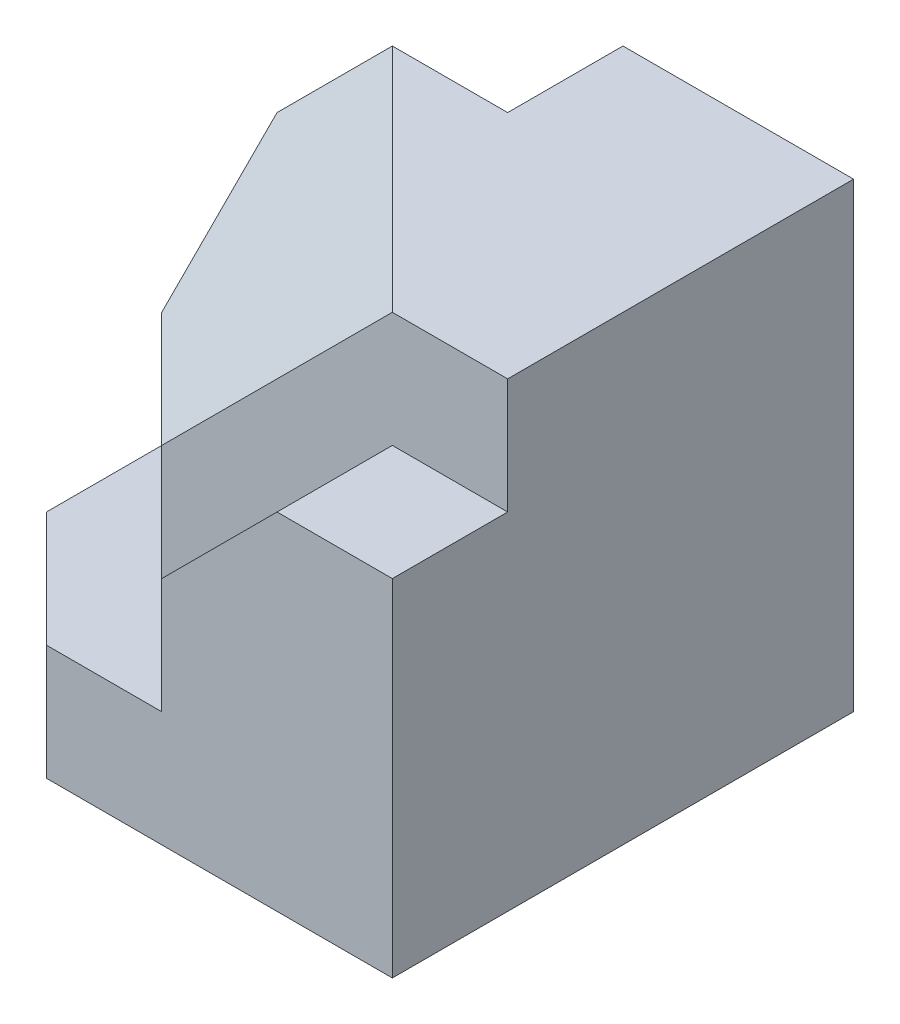
from build123d import *

# Parameters (mm, degrees)
BOSS_EXTRUDE1_DEPTH = 20
BOSS_EXTRUDE2_DEPTH = 20
CUT_EXTRUDE1_DEPTH  = 20
BOSS_EXTRUDE3_DEPTH = 5
BOSS_EXTRUDE4_DEPTH = 5
SKETCH7_W           = 5
SKETCH7_H           = 15
BOSS_EXTRUDE5_DEPTH = 10


with BuildPart() as part:
    # Sketch2 → Boss-Extrude1 (new body)
    with BuildSketch(Plane(origin=(0, 0, 0), x_dir=(1, 0, 0), z_dir=(0, 1, 0))):
        Polygon((-10, -5), (-10, 0), (0, 0), (0, -15), (-5, -15), (-15, -5), align=None)
    extrude(amount=BOSS_EXTRUDE1_DEPTH)

    # Sketch3 → Boss-Extrude2 (add)
    with BuildSketch(Plane(origin=(0, 0, 0), x_dir=(-1, 0, 0), z_dir=(0, -1, 0))):
        Polygon((15, -5), (5, -15), (15, -15), (20, -10), (20, -5), align=None)
    extrude(amount=-BOSS_EXTRUDE2_DEPTH)

    # 3DSketch2 → Cut-Extrude1 (cut, along a direction that is not the sketch's normal)
    with BuildSketch(Plane(origin=(-15, 20, 5), x_dir=(0, -0.7071067811865476, 0.7071067811865475), z_dir=(-0.5773502691896257, 0.5773502691896257, 0.5773502691896257))):
        Polygon((0, 0), (7.071067812, 12.247448714), (14.142135624, 0), (10.606601718, -6.123724357), (3.535533906, -6.123724357), align=None)
    extrude(amount=CUT_EXTRUDE1_DEPTH, dir=(0, 1, 0), mode=Mode.SUBTRACT)

    # Sketch5 → Boss-Extrude3 (add)
    with BuildSketch(Plane.XY.offset(15)):
        Polygon((0, 15), (-5, 15), (-10, 10), (-10, 5), (-15, 5), (-15, 0), (0, 0), align=None)
    extrude(amount=BOSS_EXTRUDE3_DEPTH)

    # Sketch6 → Boss-Extrude4 (add)
    with BuildSketch(Plane(origin=(0, 0, 0), x_dir=(-1, 0, 0), z_dir=(0, -1, 0))):
        Polygon((20, -10), (15, -15), (15, -20), (20, -15), align=None)
    extrude(amount=-BOSS_EXTRUDE4_DEPTH)

    # Sketch7 → Boss-Extrude5 (add)
    with BuildSketch(Plane.ZY.offset(10)):
        with Locations((2.5, 7.5)):
            Rectangle(SKETCH7_W, SKETCH7_H)
    extrude(amount=BOSS_EXTRUDE5_DEPTH)


solid = part.part
